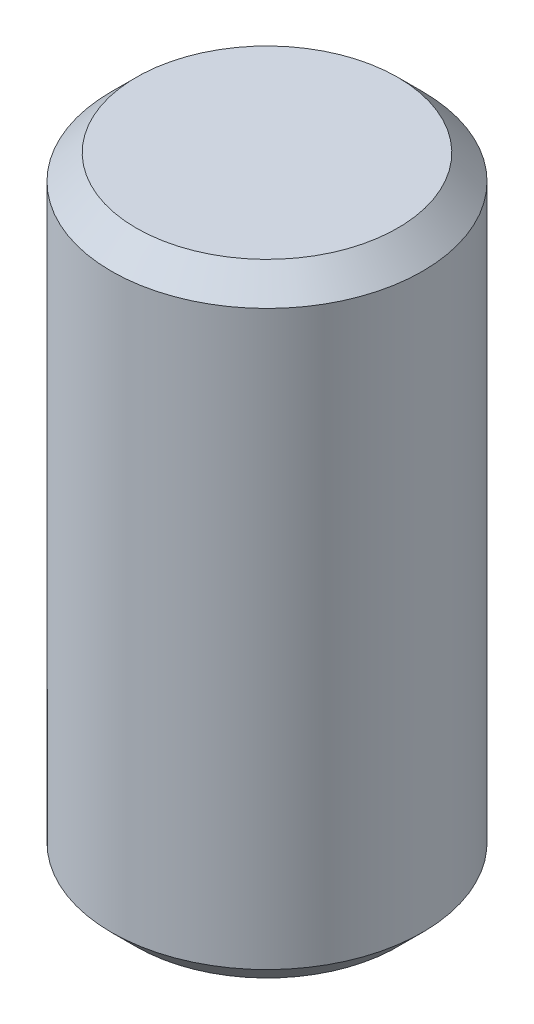
from build123d import *

# Parameters (mm, degrees)
SKETCH1_W     = 3.175
SKETCH1_H     = 12.7
CHAMFER1_SIZE = 0.508


with BuildPart() as part:
    # Sketch1 → Revolve1 (revolve)
    with BuildSketch(Plane.XY):
        with Locations((1.5875, 0)):
            Rectangle(SKETCH1_W, SKETCH1_H)
    revolve(axis=Axis((0, 6.080207887, 0), (0, -1, 0)))

    # Chamfer1
    chamfer1_edges = [part.edges().sort_by_distance(p)[0] for p in [
        (-3.175, 6.35, 0),
        (-3.175, -6.35, 0),
    ]]
    chamfer(chamfer1_edges, length=CHAMFER1_SIZE)


solid = part.part
